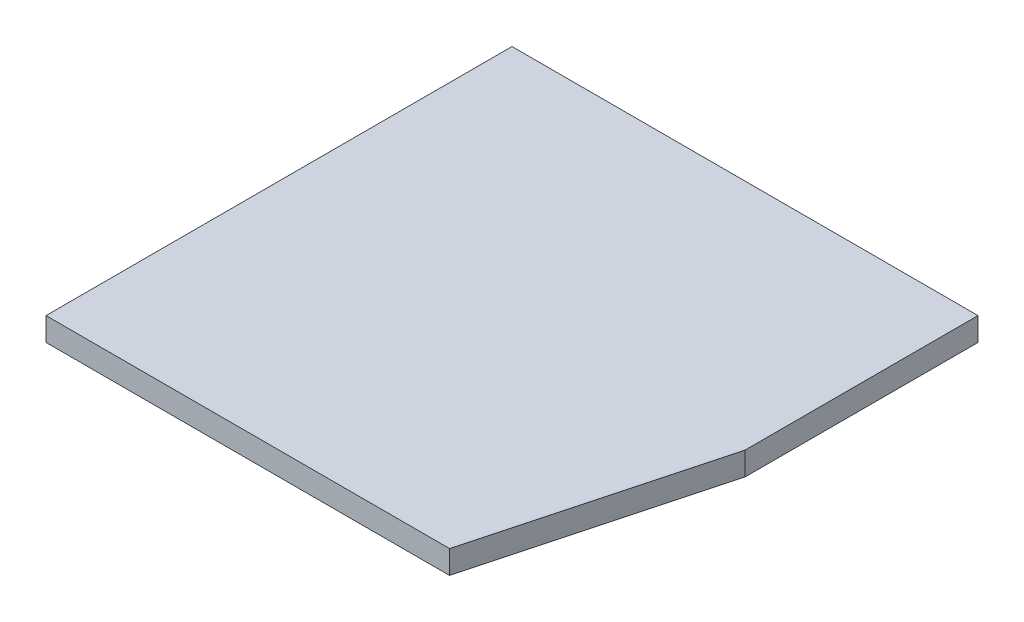
from build123d import *

# Parameters (mm, degrees)
SKETCH1_W               = 127
SKETCH1_H               = 6.35
BOSS_EXTRUDE1_DEPTH     = 127
CUT_EXTRUDE1_DEPTH      = 1
CUT_EXTRUDE1_DEPTH_BACK = 7.35


with BuildPart() as part:
    # Sketch1 → Boss-Extrude1 (new body)
    with BuildSketch(Plane.XY):
        Rectangle(SKETCH1_W, SKETCH1_H)
    extrude(amount=BOSS_EXTRUDE1_DEPTH)

    # Sketch2 → Cut-Extrude1 (cut, two sides)
    with BuildSketch(Plane.XZ.offset(3.175)) as cut_extrude1_sk:
        Polygon((63.5, 63.5), (46.485226281, 127), (63.5, 127), align=None)
    extrude(amount=CUT_EXTRUDE1_DEPTH, mode=Mode.SUBTRACT)
    extrude(cut_extrude1_sk.sketch, amount=-CUT_EXTRUDE1_DEPTH_BACK, mode=Mode.SUBTRACT)


solid = part.part
